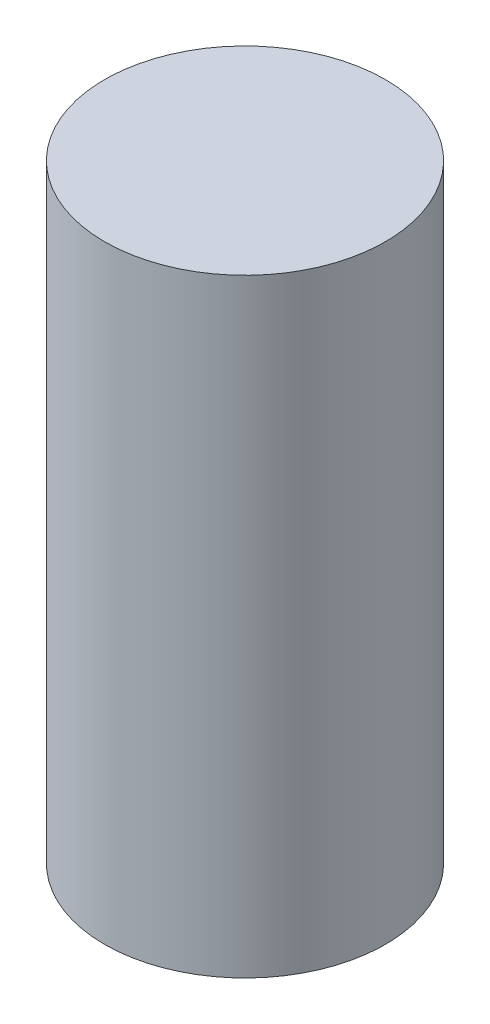
from build123d import *

# Parameters (mm, degrees)
SKETCH1_R           = 3
BOSS_EXTRUDE1_DEPTH = 13


with BuildPart() as part:
    # Sketch1 → Boss-Extrude1 (new body)
    with BuildSketch(Plane(origin=(0, 0, 0), x_dir=(1, 0, 0), z_dir=(0, 1, 0))):
        with Locations((-12.599175103, 5.122495793)):
            Circle(SKETCH1_R)
    extrude(amount=BOSS_EXTRUDE1_DEPTH)


solid = part.part
